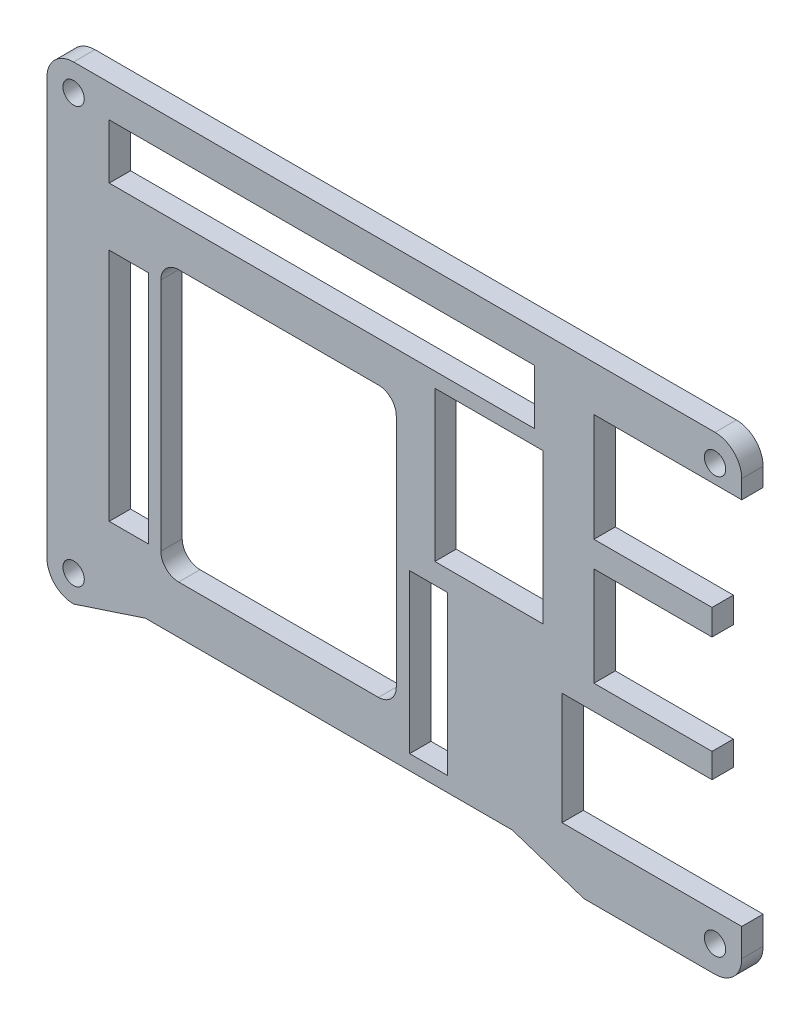
from build123d import *

# Parameters (mm, degrees)
SKETCH1_R           = 1.3462
SKETCH1_W           = 5.4034
SKETCH1_H           = 22.6066
SKETCH1_W_2         = 60.6932
SKETCH1_H_2         = 7.81
SKETCH1_W_3         = 15.431
SKETCH1_H_3         = 21.4039
SKETCH1_W_4         = 31.9679
SKETCH1_H_4         = 18.2371
SKETCH1_W_5         = 5.588
SKETCH1_H_5         = 33.5001
BOSS_EXTRUDE1_DEPTH = 3.048
SKETCH2_W           = 33.5789
SKETCH2_H           = 38.5801
CUT_EXTRUDE1_DEPTH  = 4.048
FILLET1_R           = 2.54
SKETCH3_R           = 1.524
CUT_EXTRUDE2_DEPTH  = 4.048


with BuildPart() as part:
    # Sketch1 → Boss-Extrude1 (new body)
    with BuildSketch(Plane.XY):
        with BuildLine():
            Line((61.214907375, 24.068294304), (40.134807375, 24.068294304))
            Line((40.134807375, 24.068294304), (40.134807375, 8.658194304))
            Line((40.134807375, 8.658194304), (56.975007375, 8.658194304))
            Line((56.975007375, 8.658194304), (56.975007375, 4.997894304))
            Line((56.975007375, 4.997894304), (40.134807375, 4.997894304))
            Line((40.134807375, 4.997894304), (40.134807375, -9.121805696))
            Line((40.134807375, -9.121805696), (56.975007375, -9.121805696))
            Line((56.975007375, -9.121805696), (56.975007375, -12.628005696))
            Line((56.975007375, -12.628005696), (35.575007375, -12.628005696))
            Line((35.575007375, -12.628005696), (35.575007375, -28.627805696))
            Line((35.575007375, -28.627805696), (61.214907375, -28.627805696))
            Line((61.214907375, -28.627805696), (61.214907375, -32.613401529))
            ThreePointArc((61.214907375, -32.613401529), (60.108826144, -35.325305244), (57.405007375, -36.451005696))
            Line((57.405007375, -36.451005696), (38.714307375, -36.451005696))
            Line((38.714307375, -36.451005696), (28.474307375, -33.084405696))
            Line((28.474307375, -33.084405696), (-23.844892625, -33.084405696))
            Line((-23.844892625, -33.084405696), (-34.084892625, -36.451005696))
            ThreePointArc((-34.084892625, -36.451005696), (-36.778969461, -35.335082532), (-37.894892625, -32.641005696))
            Line((-37.894892625, -32.641005696), (-37.894892625, 26.697694304))
            ThreePointArc((-37.894892625, 26.697694304), (-36.778969461, 29.391771141), (-34.084892625, 30.507694304))
            Line((-34.084892625, 30.507694304), (57.404932375, 30.507694304))
            ThreePointArc((57.404932375, 30.507694304), (60.103884597, 29.386886916), (61.214907375, 26.683892153))
            Line((61.214907375, 26.683892153), (61.214907375, 24.068294304))
        make_face()
        with Locations((57.404932375, 26.697694304)):
            Circle(SKETCH1_R, mode=Mode.SUBTRACT)
        with Locations((57.405007375, -32.641005696)):
            Circle(SKETCH1_R, mode=Mode.SUBTRACT)
        with Locations((-34.084892625, -32.641005696)):
            Circle(SKETCH1_R, mode=Mode.SUBTRACT)
        with Locations((-34.084892625, 26.697694304)):
            Circle(SKETCH1_R, mode=Mode.SUBTRACT)
        with Locations((16.546707375, -19.663505696)):
            Rectangle(SKETCH1_W, SKETCH1_H, mode=Mode.SUBTRACT)
        with Locations((1.341707375, 21.991994304)):
            Rectangle(SKETCH1_W_2, SKETCH1_H_2, mode=Mode.SUBTRACT)
        with Locations((25.156507375, 5.270444304)):
            Rectangle(SKETCH1_W_3, SKETCH1_H_3, mode=Mode.SUBTRACT)
        with Locations((-5.654942625, 1.475544304)):
            Rectangle(SKETCH1_W_4, SKETCH1_H_4, mode=Mode.SUBTRACT)
        with Locations((-26.210892625, -6.948855696)):
            Rectangle(SKETCH1_W_5, SKETCH1_H_5, mode=Mode.SUBTRACT)
    extrude(amount=BOSS_EXTRUDE1_DEPTH)

    # Sketch2 → Cut-Extrude1 (cut, through all)
    with BuildSketch(Plane.XY.offset(3.048)):
        with Locations((-4.849442625, -6.948855696)):
            Rectangle(SKETCH2_W, SKETCH2_H)
    extrude(amount=-CUT_EXTRUDE1_DEPTH, mode=Mode.SUBTRACT)

    # Fillet1
    fillet1_edges = [part.edges().sort_by_distance(p)[0] for p in [
        (-21.638892625, -26.238905696, 1.524),
        (11.940007375, 12.341194304, 1.524),
        (11.940007375, -26.238905696, 1.524),
        (-21.638892625, 12.341194304, 1.524),
    ]]
    fillet(fillet1_edges, radius=FILLET1_R)

    # Sketch3 → Cut-Extrude2 (cut, through all)
    with BuildSketch(Plane.XY.offset(3.048)):
        with Locations((-34.084892625, 26.697694304)):
            Circle(SKETCH3_R)
        with Locations((57.404932375, 26.697694304)):
            Circle(SKETCH3_R)
        with Locations((57.405007375, -32.641005696)):
            Circle(SKETCH3_R)
        with Locations((-34.084892625, -32.641005696)):
            Circle(SKETCH3_R)
    extrude(amount=-CUT_EXTRUDE2_DEPTH, mode=Mode.SUBTRACT)


solid = part.part
